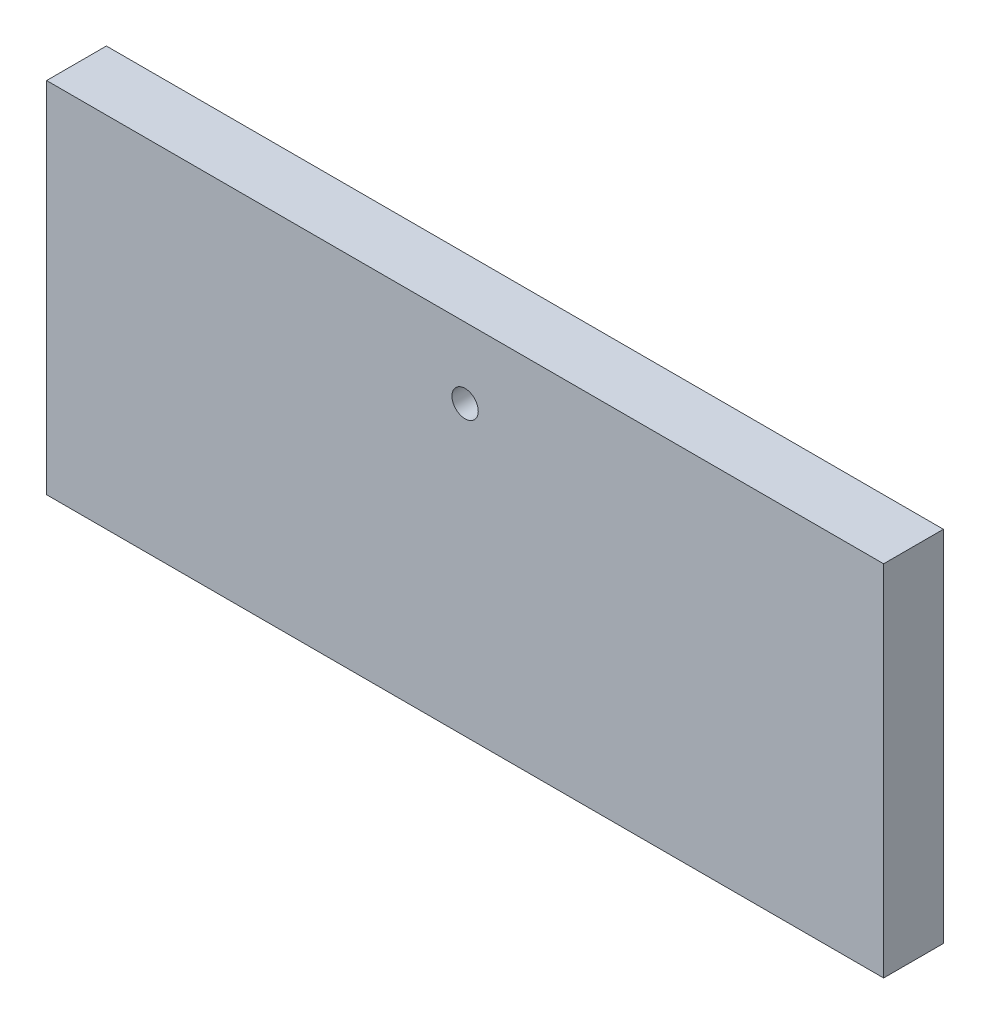
from build123d import *

# Parameters (mm, degrees)
SKETCH1_W               = 700
SKETCH1_H               = 300
BOSS_EXTRUDE1_DEPTH     = 25
SKETCH2_R               = 11
CUT_EXTRUDE1_DEPTH      = 26
CUT_EXTRUDE1_DEPTH_BACK = 26


with BuildPart() as part:
    # Sketch1 → Boss-Extrude1 (new body, symmetric)
    with BuildSketch(Plane.XY):
        with Locations((0, 150)):
            Rectangle(SKETCH1_W, SKETCH1_H)
    extrude(amount=BOSS_EXTRUDE1_DEPTH, both=True)

    # Sketch2 → Cut-Extrude1 (cut, two sides)
    with BuildSketch(Plane.XY) as cut_extrude1_sk:
        with Locations((0, 241)):
            Circle(SKETCH2_R)
    extrude(amount=CUT_EXTRUDE1_DEPTH, mode=Mode.SUBTRACT)
    extrude(cut_extrude1_sk.sketch, amount=-CUT_EXTRUDE1_DEPTH_BACK, mode=Mode.SUBTRACT)


solid = part.part
